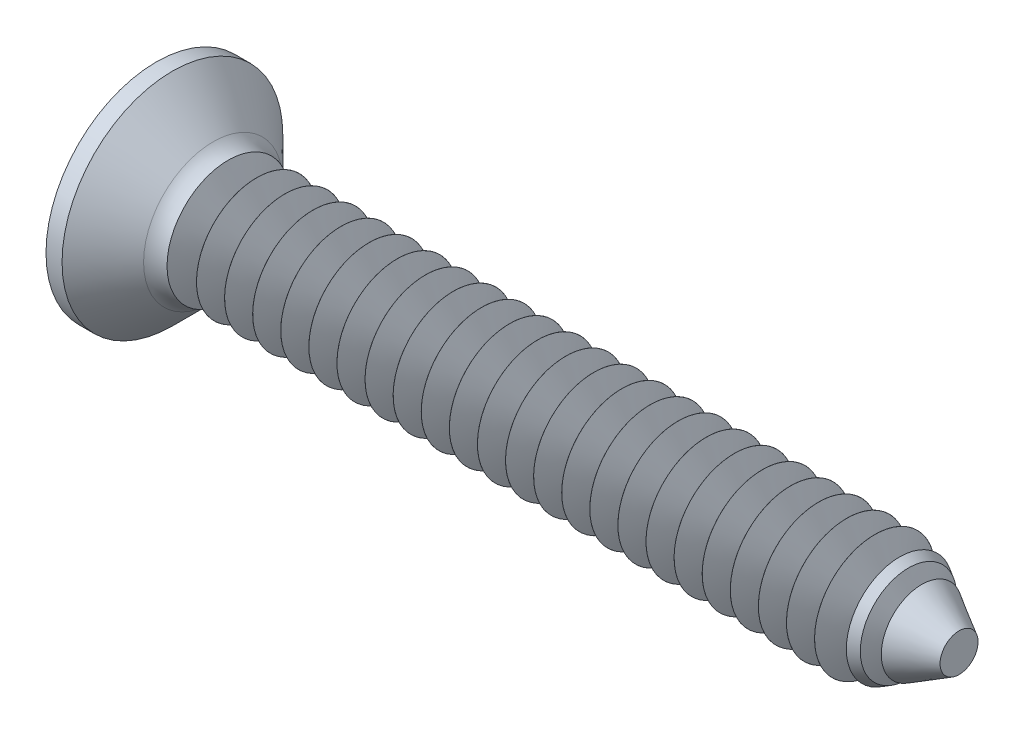
from build123d import *

# Parameters (mm, degrees)
FILLET1_R       = 0.8
SKETCH3_W       = 0.74
SKETCH3_H       = 3
SKETCH4_W       = 0.74
SKETCH4_H       = 0.995702004
RECPAT_COUNT    = 2
RECPAT_ANGLE    = 90
THDSCHPAT_COUNT = 26
THDSCHPAT_PITCH = 0.7


with BuildPart() as part:
    # BodySke → Base-Revolve (revolve)
    with BuildSketch(Plane.XY, mode=Mode.PRIVATE) as base_revolve_sk:
        Polygon((0, 0), (0, 2.75), (0.4, 2.75), (1.65, 1.5), (18.220901985, 1.5), (20, 0.472837282), (20, 0), align=None)
    revolve(base_revolve_sk.sketch.rotate(Axis((-6.35, 0, 0), (1, 0, 0)), 90), axis=Axis((-6.35, 0, 0), (1, 0, 0)))  # turned: the seam where the file's is

    # Fillet1
    fillet1_edges = [part.edges().sort_by_distance(p)[0] for p in [
        (1.65, 0, -1.5),
    ]]
    fillet(fillet1_edges, radius=FILLET1_R)

    # Sketch3 → Recess section 0
    with BuildSketch(Plane.ZY):
        Rectangle(SKETCH3_W, SKETCH3_H)
    # Sketch4 → Recess section 1
    with BuildSketch(Plane.ZY.offset(-2.01)):
        Rectangle(SKETCH4_W, SKETCH4_H)
    recess = loft(mode=Mode.SUBTRACT)

    # RecPat: Recess ×2 about axis
    recpat_axis = Axis((0, 0, 0), (1, 0, 0))
    for i in range(1, RECPAT_COUNT):
        add(recess.rotate(recpat_axis, i * RECPAT_ANGLE / (RECPAT_COUNT - 1)), mode=Mode.SUBTRACT)

    # RecCorSke → RecessCore (revolve, cut)
    with BuildSketch(Plane.XY, mode=Mode.PRIVATE) as recesscore_sk:
        Polygon((0, 0), (0, 0.696552892), (2.01, 0.556), (2.190655351, 0), align=None)
    revolve(recesscore_sk.sketch.rotate(Axis((-3.175, 0, 0), (1, 0, 0)), 90), axis=Axis((-3.175, 0, 0), (1, 0, 0)), mode=Mode.SUBTRACT)  # turned: the seam where the file's is

    # ThdSchSke → ThreadSchematic (revolve, cut)
    with BuildSketch(Plane.XY, mode=Mode.PRIVATE) as threadschematic_sk:
        Polygon((2.150001, -0.75), (1.567116427, -2), (1.567116427, -3), (2.732885573, -3), (2.732885573, -2), align=None)
    threadschematic = revolve(threadschematic_sk.sketch.rotate(Axis((-3.175, 0, 0), (1, 0, 0)), 270), axis=Axis((-3.175, 0, 0), (1, 0, 0)), mode=Mode.SUBTRACT)  # turned: the seam where the file's is

    # ThdSchPat: ThreadSchematic ×26
    with Locations(*[(i * THDSCHPAT_PITCH, 0, 0) for i in range(1, THDSCHPAT_COUNT)]):
        add(threadschematic, mode=Mode.SUBTRACT)


solid = part.part
